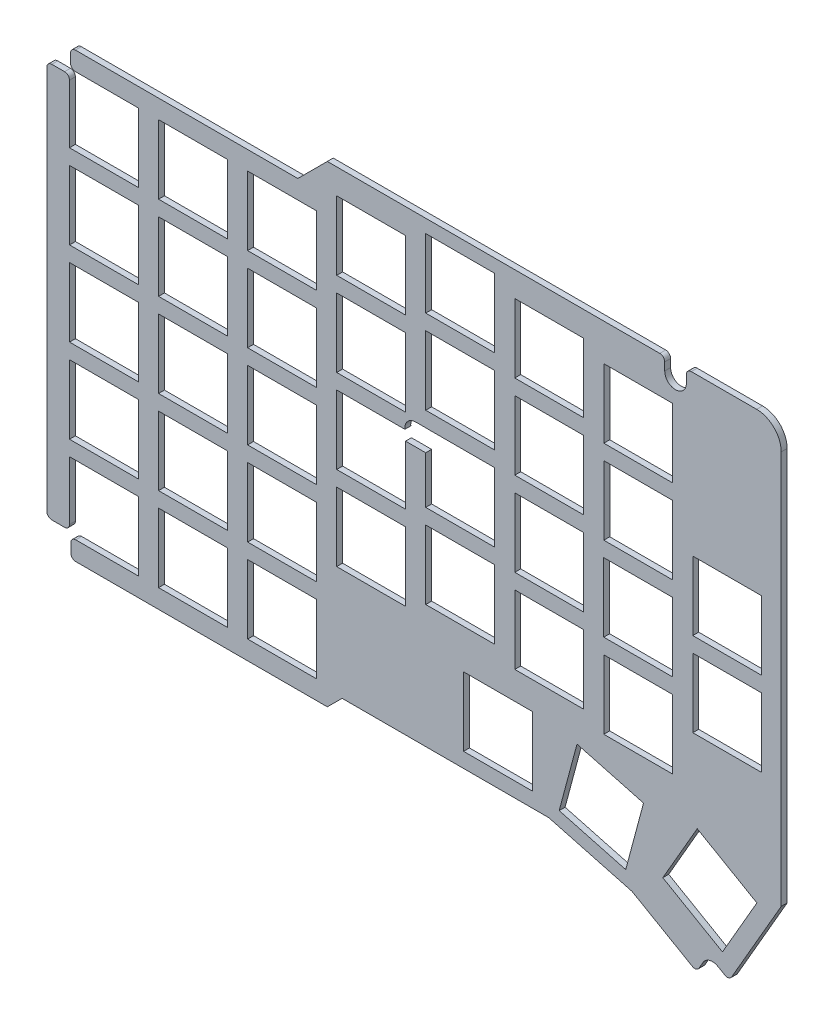
from build123d import *

# Parameters (mm, degrees)
SKETCH1_W           = 14
SKETCH1_H           = 14
BOSS_EXTRUDE2_DEPTH = 1.2
FILLET1_R           = 1
CUT_EXTRUDE2_REACH  = 3.2
SKETCH2_R           = 2.2


with BuildPart() as part:
    # Sketch1 → Boss-Extrude2 (new body)
    with BuildSketch(Plane.XY):
        with BuildLine():
            Line((81.33, -202.9), (79.33, -202.9))
            Line((79.33, -202.9), (76.73, -202.9))
            Line((76.73, -202.9), (76.73, -212.03))
            Line((76.73, -212.03), (76.73, -283.1))
            Line((76.73, -283.1), (79.4, -283.1))
            Line((79.4, -283.1), (81.33, -283.1))
            Line((81.33, -283.1), (81.33, -270.169))
            Line((81.33, -270.169), (95.33, -270.169))
            Line((95.33, -270.169), (95.33, -284.169))
            Line((95.33, -284.169), (81.6, -284.169))
            Line((81.6, -284.169), (81.6, -285.300000001))
            Line((81.6, -285.300000001), (81.6, -288.000000001))
            Line((81.6, -288.000000001), (104.85, -288.000000001))
            Line((104.85, -288.000000001), (113.94, -288.000000001))
            Line((113.94, -288.000000001), (133.73, -288.000000001))
            Line((133.73, -288.000000001), (136.73, -285.000000001))
            Line((136.73, -285.000000001), (152.86, -285.000000001))
            Line((152.86, -285.000000001), (161.94, -285.000000001))
            Line((161.94, -285.000000001), (178.73, -285.000000001))
            Line((178.73, -285.000000001), (195.659492, -289.51666))
            Line((195.659492, -289.51666), (208.778384908, -297.081045818))
            Line((208.778384908, -297.081045818), (210.094127263, -294.801069106))
            Line((210.094127263, -294.801069106), (210.094924986, -294.799686776))
            ThreePointArc((210.094924986, -294.799686776), (211.43094748, -293.774869597), (213.100313224, -293.994924986))
            Line((213.100313224, -293.994924986), (215.397829273, -295.321900182))
            Line((215.397829273, -295.321900182), (225.98, -277))
            Line((225.98, -277), (225.98, -256.415))
            Line((225.98, -256.415), (225.98, -247.025))
            Line((225.98, -247.025), (225.98, -214.605))
            Line((225.98, -214.605), (225.98, -205.215))
            Line((225.98, -205.215), (225.98, -197))
            ThreePointArc((225.98, -197), (224.515534, -193.464466), (220.98, -192))
            Line((220.98, -192), (206.7, -192))
            Line((206.7, -192), (206.7, -194.6))
            ThreePointArc((206.7, -194.6), (204.5, -196.8), (202.3, -194.6))
            Line((202.3, -194.6), (202.3, -192))
            Line((202.3, -192), (179.02, -192))
            Line((179.02, -192), (169.96, -192))
            Line((169.96, -192), (136.73, -192))
            Line((136.73, -192), (133.73, -192))
            Line((133.73, -192), (127.73, -198))
            Line((127.73, -198), (108.89, -198))
            Line((108.89, -198), (99.78, -198))
            Line((99.78, -198), (82.73, -198))
            Line((82.73, -198), (81.53, -198))
            Line((81.53, -198), (81.53, -200.7))
            Line((81.53, -200.7), (81.53, -201.794))
            Line((81.53, -201.794), (95.33, -201.794))
            Line((95.33, -201.794), (95.33, -215.794))
            Line((95.33, -215.794), (81.33, -215.794))
            Line((81.33, -215.794), (81.33, -202.9))
        make_face()
        with Locations((106.43, -277.169)):
            Rectangle(SKETCH1_W, SKETCH1_H, mode=Mode.SUBTRACT)
        with Locations((124.53, -277.169)):
            Rectangle(SKETCH1_W, SKETCH1_H, mode=Mode.SUBTRACT)
        with Locations((88.33, -260.094)):
            Rectangle(SKETCH1_W, SKETCH1_H, mode=Mode.SUBTRACT)
        with Locations((106.43, -260.094)):
            Rectangle(SKETCH1_W, SKETCH1_H, mode=Mode.SUBTRACT)
        with Locations((124.53, -260.094)):
            Rectangle(SKETCH1_W, SKETCH1_H, mode=Mode.SUBTRACT)
        with Locations((142.63, -255.362582)):
            Rectangle(SKETCH1_W, SKETCH1_H, mode=Mode.SUBTRACT)
        with Locations((168.416577, -274.987582)):
            Rectangle(SKETCH1_W, SKETCH1_H, mode=Mode.SUBTRACT)
        Polygon((194.375574468, -286.3230671), (180.8526129, -282.699600468), (184.476079532, -269.1766389), (197.9990411, -272.800105532), align=None, mode=Mode.SUBTRACT)
        Polygon((221.036025826, -278.856733174), (214.036025826, -290.981088826), (201.911670174, -283.981088826), (208.911670174, -271.856733174), align=None, mode=Mode.SUBTRACT)
        with Locations((160.73, -252.987582)):
            Rectangle(SKETCH1_W, SKETCH1_H, mode=Mode.SUBTRACT)
        with Locations((178.83, -255.362582)):
            Rectangle(SKETCH1_W, SKETCH1_H, mode=Mode.SUBTRACT)
        with Locations((196.916577, -257.737582)):
            Rectangle(SKETCH1_W, SKETCH1_H, mode=Mode.SUBTRACT)
        with Locations((215.005, -248.412582)):
            Rectangle(SKETCH1_W, SKETCH1_H, mode=Mode.SUBTRACT)
        with Locations((88.33, -242.994)):
            Rectangle(SKETCH1_W, SKETCH1_H, mode=Mode.SUBTRACT)
        with Locations((106.43, -242.994)):
            Rectangle(SKETCH1_W, SKETCH1_H, mode=Mode.SUBTRACT)
        with Locations((88.33, -225.894)):
            Rectangle(SKETCH1_W, SKETCH1_H, mode=Mode.SUBTRACT)
        with Locations((106.43, -225.894)):
            Rectangle(SKETCH1_W, SKETCH1_H, mode=Mode.SUBTRACT)
        with Locations((124.53, -242.994)):
            Rectangle(SKETCH1_W, SKETCH1_H, mode=Mode.SUBTRACT)
        with Locations((142.63, -238.269)):
            Rectangle(SKETCH1_W, SKETCH1_H, mode=Mode.SUBTRACT)
        with Locations((124.53, -225.894)):
            Rectangle(SKETCH1_W, SKETCH1_H, mode=Mode.SUBTRACT)
        with Locations((142.63, -221.194)):
            Rectangle(SKETCH1_W, SKETCH1_H, mode=Mode.SUBTRACT)
        with Locations((106.43, -208.794)):
            Rectangle(SKETCH1_W, SKETCH1_H, mode=Mode.SUBTRACT)
        with Locations((124.53, -208.794)):
            Rectangle(SKETCH1_W, SKETCH1_H, mode=Mode.SUBTRACT)
        with Locations((142.63, -204.094)):
            Rectangle(SKETCH1_W, SKETCH1_H, mode=Mode.SUBTRACT)
        with Locations((160.73, -235.894)):
            Rectangle(SKETCH1_W, SKETCH1_H, mode=Mode.SUBTRACT)
        with Locations((178.83, -238.269)):
            Rectangle(SKETCH1_W, SKETCH1_H, mode=Mode.SUBTRACT)
        with Locations((160.73, -218.794)):
            Rectangle(SKETCH1_W, SKETCH1_H, mode=Mode.SUBTRACT)
        with Locations((178.83, -221.169)):
            Rectangle(SKETCH1_W, SKETCH1_H, mode=Mode.SUBTRACT)
        with Locations((196.905, -240.644)):
            Rectangle(SKETCH1_W, SKETCH1_H, mode=Mode.SUBTRACT)
        with Locations((196.93, -223.569)):
            Rectangle(SKETCH1_W, SKETCH1_H, mode=Mode.SUBTRACT)
        with Locations((215.005, -231.319)):
            Rectangle(SKETCH1_W, SKETCH1_H, mode=Mode.SUBTRACT)
        with Locations((160.73, -201.694)):
            Rectangle(SKETCH1_W, SKETCH1_H, mode=Mode.SUBTRACT)
        with Locations((178.83, -204.069)):
            Rectangle(SKETCH1_W, SKETCH1_H, mode=Mode.SUBTRACT)
        with Locations((196.93, -206.494)):
            Rectangle(SKETCH1_W, SKETCH1_H, mode=Mode.SUBTRACT)
    extrude(amount=BOSS_EXTRUDE2_DEPTH)

    # Fillet1
    fillet1_edges = [part.edges().sort_by_distance(p)[0] for p in [
        (208.778384908, -297.081045818, 0.6),
        (81.6, -288.000000001, 0.6),
        (81.6, -284.169, 0.6),
        (81.33, -283.1, 0.6),
        (76.73, -283.1, 0.6),
        (76.73, -202.9, 0.6),
        (81.33, -202.9, 0.6),
        (81.53, -201.794, 0.6),
        (81.53, -198, 0.6),
        (202.3, -192, 0.6),
        (206.7, -192, 0.6),
        (215.397829273, -295.321900182, 0.6),
    ]]
    fillet(fillet1_edges, radius=FILLET1_R)

    # Sketch2 → Cut-Extrude2 (cut, up to next)
    with BuildSketch(Plane.XY.offset(1.2), mode=Mode.PRIVATE) as cut_extrude2_sk1:
        with BuildLine():
            Line((153.73, -228.88), (151.68, -228.88))
            ThreePointArc((151.68, -228.88), (152.921660353, -229.263883383), (153.73, -230.281564029))
            Line((153.73, -230.281564029), (153.73, -228.894))
            Line((153.73, -228.894), (153.73, -228.88))
        make_face()
    cut_extrude2_tool1 = extrude(cut_extrude2_sk1.sketch, amount=-CUT_EXTRUDE2_REACH, mode=Mode.PRIVATE) & part.part
    add(cut_extrude2_tool1.solids().sort_by_distance((153.255364, -229.260338, 1.2))[0], mode=Mode.SUBTRACT)
    # Sketch2 → Cut-Extrude2 (cut, up to next)
    with BuildSketch(Plane.XY.offset(1.2), mode=Mode.PRIVATE) as cut_extrude2_sk2:
        with Locations((151.68, -231.08)):
            Circle(SKETCH2_R)
    cut_extrude2_tool2 = extrude(cut_extrude2_sk2.sketch, amount=-CUT_EXTRUDE2_REACH, mode=Mode.PRIVATE) & part.part
    add(cut_extrude2_tool2.solids().sort_by_distance((151.68, -231.08, 1.2))[0], mode=Mode.SUBTRACT)
    # Sketch2 → Cut-Extrude2 (cut, up to next)
    with BuildSketch(Plane.XY.offset(1.2), mode=Mode.PRIVATE) as cut_extrude2_sk3:
        with BuildLine():
            ThreePointArc((153.73, -231.878435971), (152.921660353, -232.896116617), (151.68, -233.28))
            Line((151.68, -233.28), (153.73, -233.28))
            Line((153.73, -233.28), (153.73, -231.878435971))
        make_face()
    cut_extrude2_tool3 = extrude(cut_extrude2_sk3.sketch, amount=-CUT_EXTRUDE2_REACH, mode=Mode.PRIVATE) & part.part
    add(cut_extrude2_tool3.solids().sort_by_distance((153.255364, -232.899662, 1.2))[0], mode=Mode.SUBTRACT)
    # Sketch2 → Cut-Extrude2 (cut, up to next)
    with BuildSketch(Plane.XY.offset(1.2), mode=Mode.PRIVATE) as cut_extrude2_sk4:
        with BuildLine():
            ThreePointArc((151.68, -233.28), (150.438339647, -232.896116617), (149.63, -231.878435971))
            Line((149.63, -231.878435971), (149.63, -233.28))
            Line((149.63, -233.28), (151.68, -233.28))
        make_face()
    cut_extrude2_tool4 = extrude(cut_extrude2_sk4.sketch, amount=-CUT_EXTRUDE2_REACH, mode=Mode.PRIVATE) & part.part
    add(cut_extrude2_tool4.solids().sort_by_distance((150.104636, -232.899662, 1.2))[0], mode=Mode.SUBTRACT)


solid = part.part
